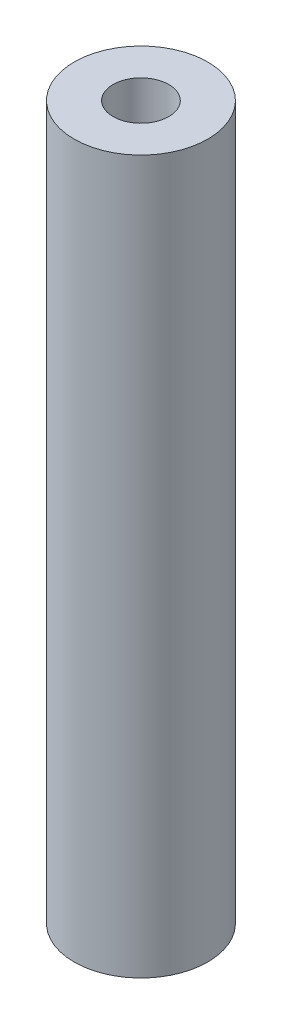
from build123d import *

# Parameters (mm, degrees)
SKETCH1_R                   = 3
BOSS_EXTRUDE1_DEPTH         = 32
TAP_DRILL_FOR_M3_TAP1_D     = 2.5
TAP_DRILL_FOR_M3_TAP1_DEPTH = 10
TAP_DRILL_FOR_M3_TAP1_TIP   = 0.751075774
TAP_DRILL_FOR_M3_TAP2_D     = 2.5
TAP_DRILL_FOR_M3_TAP2_DEPTH = 10
TAP_DRILL_FOR_M3_TAP2_TIP   = 0.751075774


with BuildPart() as part:
    # Sketch1 → Boss-Extrude1 (new body)
    with BuildSketch(Plane(origin=(0, 0, 0), x_dir=(1, 0, 0), z_dir=(0, 1, 0))):
        Circle(SKETCH1_R)
    extrude(amount=BOSS_EXTRUDE1_DEPTH)

    # Tap Drill for M3 Tap1
    with Locations(Plane(origin=(0, 32, 0), x_dir=(1, 0, 0), z_dir=(0, 1, 0))):
        with Locations((0, 0)):
            Hole(TAP_DRILL_FOR_M3_TAP1_D / 2, depth=TAP_DRILL_FOR_M3_TAP1_DEPTH)
            with Locations((0, 0, -(TAP_DRILL_FOR_M3_TAP1_DEPTH + TAP_DRILL_FOR_M3_TAP1_TIP / 2))):  # 118° drill point
                Cone(0, TAP_DRILL_FOR_M3_TAP1_D / 2, TAP_DRILL_FOR_M3_TAP1_TIP, mode=Mode.SUBTRACT)

    # Tap Drill for M3 Tap2
    with Locations(Plane(origin=(0, 0, 0), x_dir=(-1, 0, 0), z_dir=(0, -1, 0))):
        with Locations((0, 0)):
            Hole(TAP_DRILL_FOR_M3_TAP2_D / 2, depth=TAP_DRILL_FOR_M3_TAP2_DEPTH)
            with Locations((0, 0, -(TAP_DRILL_FOR_M3_TAP2_DEPTH + TAP_DRILL_FOR_M3_TAP2_TIP / 2))):  # 118° drill point
                Cone(0, TAP_DRILL_FOR_M3_TAP2_D / 2, TAP_DRILL_FOR_M3_TAP2_TIP, mode=Mode.SUBTRACT)


solid = part.part
